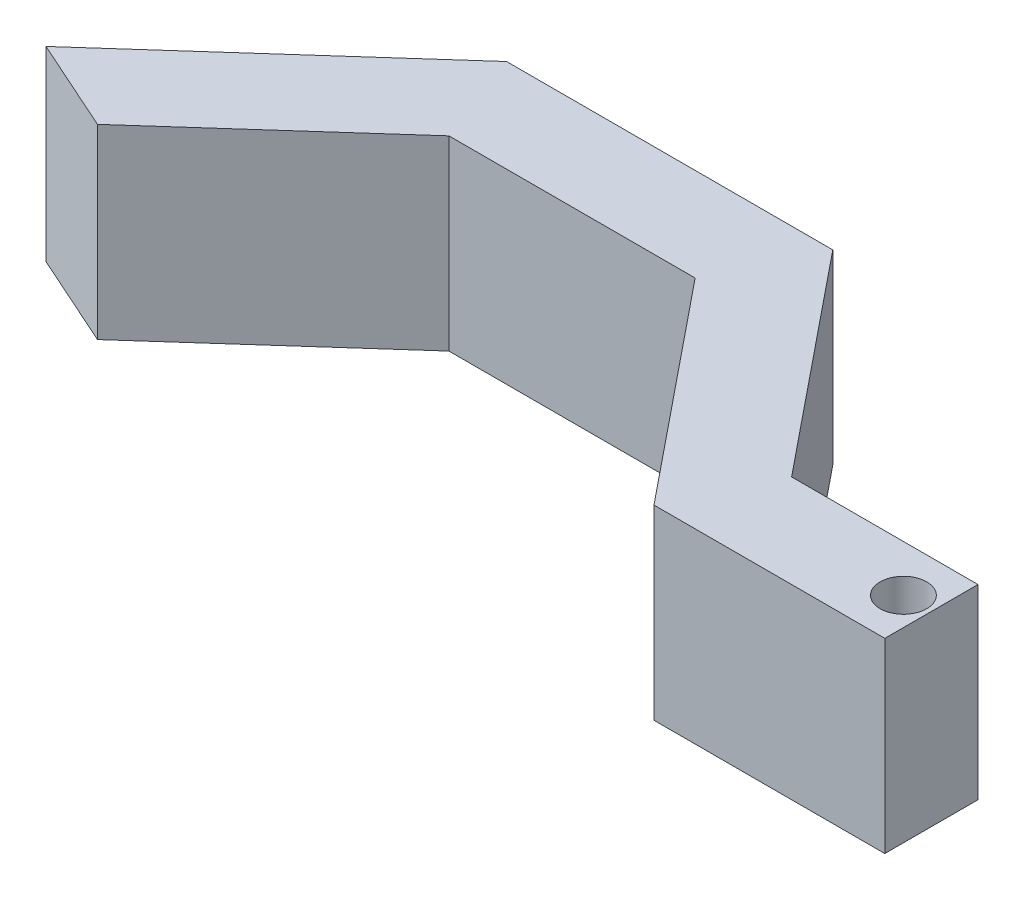
from build123d import *

# Parameters (mm, degrees)
BOSS_EXTRUDE1_DEPTH      = 10
BOSS_EXTRUDE1_DEPTH_BACK = 10
SKETCH2_R                = 2.5
CUT_EXTRUDE1_DEPTH       = 4
SPLIT2_SURFACE_1_BACK    = 108.282
SPLIT2_SURFACE_1_DEPTH   = 216.564


with BuildPart() as part:
    # Sketch1 → Boss-Extrude1 (new, two sides)
    with BuildSketch(Plane(origin=(0, 0, 0), x_dir=(1, 0, 0), z_dir=(0, 1, 0))) as boss_extrude1_sk:
        Polygon((-51.374196063, 7.601926758), (-51.374196063, -2.398073242), (-41.374196063, -2.398073242), (-41.374196063, 3.123704189), (-21.449234595, 20.908790051), (4.969602102, 20.908790051), (23.858490991, -2.398073242), (48.625803937, -2.398073242), (48.625803937, 7.601926758), (28.625803937, 7.601926758), (9.736915048, 30.908790051), (-25.263084952, 30.908790051), align=None)
    extrude(amount=BOSS_EXTRUDE1_DEPTH)
    extrude(boss_extrude1_sk.sketch, amount=-BOSS_EXTRUDE1_DEPTH_BACK)

    # Sketch2 → Cut-Extrude1 (cut)
    with BuildSketch(Plane(origin=(0, 10, 0), x_dir=(1, 0, 0), z_dir=(0, 1, 0))):
        with Locations(Location((45.625803937, 2.601926758, 0), (0, 0, 270))):
            Circle(SKETCH2_R)
    extrude(amount=-CUT_EXTRUDE1_DEPTH, mode=Mode.SUBTRACT)

    # Split2: cut with a surface, the side behind it stays
    # Split2 surface: a surface, the sketch's curves swept straight by 216.564 mm
    with BuildLine(Plane(origin=(0, -10, 0), x_dir=(-1, 0, 0), z_dir=(0, -1, 0)).offset(-SPLIT2_SURFACE_1_BACK), mode=Mode.PRIVATE) as split2_surface_1_path:
        Line((51.374196063, 7.601926758), (41.374196063, 3.123704189))
    split2_surface_1 = Shell.extrude(split2_surface_1_path.wire(), (0 * SPLIT2_SURFACE_1_DEPTH, -1 * SPLIT2_SURFACE_1_DEPTH, 0 * SPLIT2_SURFACE_1_DEPTH))
    split(bisect_by=split2_surface_1, keep=Keep.BOTTOM)


solid = part.part
